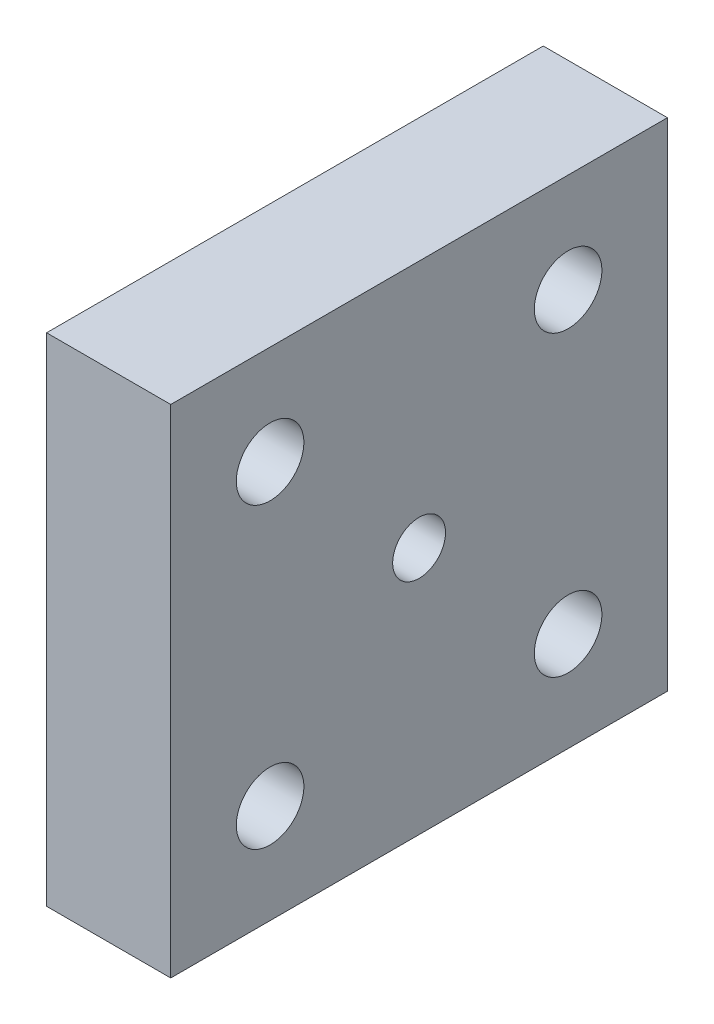
from build123d import *

# Parameters (mm, degrees)
SKETCH1_W             = 25.4
SKETCH1_H             = 25.4
BOSS_EXTRUDE1_DEPTH   = 6.35
F_8_32_TAPPED_HOLE5_D = 3.4544
F_6_32_TAPPED_HOLE1_D = 2.7051


with BuildPart() as part:
    # Sketch1 → Boss-Extrude1 (new body)
    with BuildSketch(Plane(origin=(0, 0, 0), x_dir=(0, 0, -1), z_dir=(1, 0, 0))):
        with Locations((12.7, -12.7)):
            Rectangle(SKETCH1_W, SKETCH1_H)
    extrude(amount=BOSS_EXTRUDE1_DEPTH)

    # #8-32 Tapped Hole5 (through all)
    with Locations(Plane.ZY):
        with Locations((-20.32, -20.32), (-20.32, -5.08), (-5.08, -5.08), (-5.08, -20.32)):
            Hole(F_8_32_TAPPED_HOLE5_D / 2)

    # #6-32 Tapped Hole1 (through all)
    with Locations(Plane.ZY):
        with Locations((-12.7, -12.7)):
            Hole(F_6_32_TAPPED_HOLE1_D / 2)


solid = part.part
